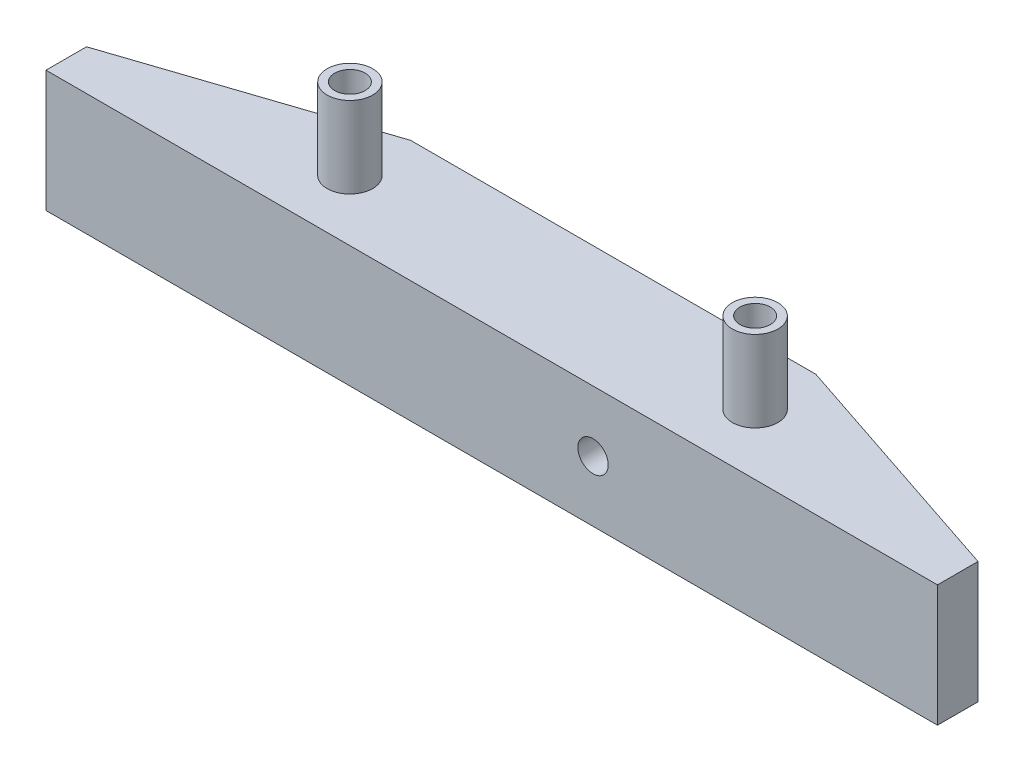
from build123d import *

# Parameters (mm, degrees)
BOSS_EXTRUDE1_DEPTH = 12
SKETCH2_R           = 2.5
CUT_EXTRUDE1_DEPTH  = 5
SKETCH3_R           = 1.5
CUT_EXTRUDE2_DEPTH  = 90.089842294
SKETCH4_R           = 2.25
SKETCH4_R_2         = 1.5
BOSS_EXTRUDE2_DEPTH = 8
SKETCH5_R           = 5
CUT_EXTRUDE3_DEPTH  = 3
SKETCH6_R           = 1.5
CUT_EXTRUDE4_DEPTH  = 91.691785736


with BuildPart() as part:
    # Sketch1 → Boss-Extrude1 (new body)
    with BuildSketch(Plane(origin=(0, 0, 0), x_dir=(1, 0, 0), z_dir=(0, 1, 0))):
        Polygon((0, 0), (88, 0), (88, 4), (64, 12), (24, 12), (0, 4), align=None)
    extrude(amount=BOSS_EXTRUDE1_DEPTH)

    # Sketch2 → Cut-Extrude1 (cut)
    with BuildSketch(Plane(origin=(0, 0, 0), x_dir=(-1, 0, 0), z_dir=(0, -1, 0))):
        with Locations(Location((-24, 6, 0), (0, 0, 90))):
            Circle(SKETCH2_R)
        with Locations(Location((-64, 6, 0), (0, 0, 90))):
            Circle(SKETCH2_R)
    extrude(amount=-CUT_EXTRUDE1_DEPTH, mode=Mode.SUBTRACT)

    # Sketch3 → Cut-Extrude2 (cut, through all)
    with BuildSketch(Plane(origin=(0, 5, 0), x_dir=(-1, 0, 0), z_dir=(0, -1, 0))):
        with Locations(Location((-24, 6, 0), (0, 0, 90))):
            Circle(SKETCH3_R)
        with Locations(Location((-64, 6, 0), (0, 0, 90))):
            Circle(SKETCH3_R)
    extrude(amount=-CUT_EXTRUDE2_DEPTH, mode=Mode.SUBTRACT)

    # Sketch4 → Boss-Extrude2 (add)
    with BuildSketch(Plane(origin=(0, 12, 0), x_dir=(1, 0, 0), z_dir=(0, 1, 0))):
        with Locations(Location((24, 6, 0), (0, 0, 270))):
            Circle(SKETCH4_R)
        with Locations(Location((24, 6, 0), (0, 0, 90))):
            Circle(SKETCH4_R_2, mode=Mode.SUBTRACT)
        with Locations(Location((64, 6, 0), (0, 0, 270))):
            Circle(SKETCH4_R)
        with Locations(Location((64, 6, 0), (0, 0, 90))):
            Circle(SKETCH4_R_2, mode=Mode.SUBTRACT)
    extrude(amount=BOSS_EXTRUDE2_DEPTH)

    # Sketch5 → Cut-Extrude3 (cut)
    with BuildSketch(Plane(origin=(0, 0, -12), x_dir=(-1, 0, 0), z_dir=(0, 0, -1))):
        with Locations((-54, 6)):
            Circle(SKETCH5_R)
    extrude(amount=-CUT_EXTRUDE3_DEPTH, mode=Mode.SUBTRACT)

    # Sketch6 → Cut-Extrude4 (cut, through all)
    with BuildSketch(Plane(origin=(0, 0, -9), x_dir=(-1, 0, 0), z_dir=(0, 0, -1))):
        with Locations((-54, 6)):
            Circle(SKETCH6_R)
    extrude(amount=-CUT_EXTRUDE4_DEPTH, mode=Mode.SUBTRACT)


solid = part.part
